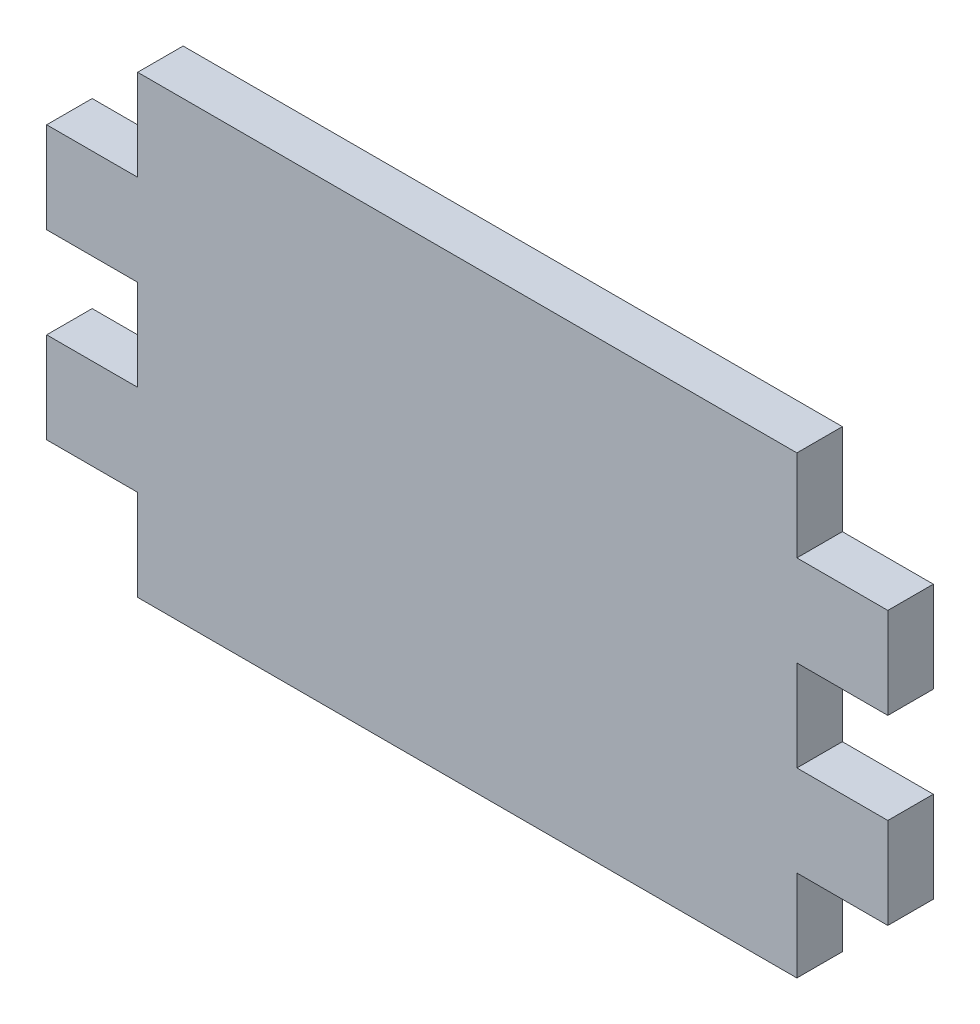
from build123d import *

# Parameters (mm, degrees)
BOSS_EXTRUDE1_DEPTH = 3.175


with BuildPart() as part:
    # Sketch1 → Boss-Extrude1 (new body)
    with BuildSketch(Plane.XY):
        Polygon((0, 0), (-46.0248, 0), (-46.0248, 6.35), (-52.3748, 6.35), (-52.3748, 12.7), (-46.0248, 12.7), (-46.0248, 19.05), (-52.3748, 19.05), (-52.3748, 25.4), (-46.0248, 25.4), (-46.0248, 31.75), (0, 31.75), (0, 25.4), (6.35, 25.4), (6.35, 19.05), (0, 19.05), (0, 12.7), (6.35, 12.7), (6.35, 6.35), (0, 6.35), align=None)
    extrude(amount=BOSS_EXTRUDE1_DEPTH)


solid = part.part
